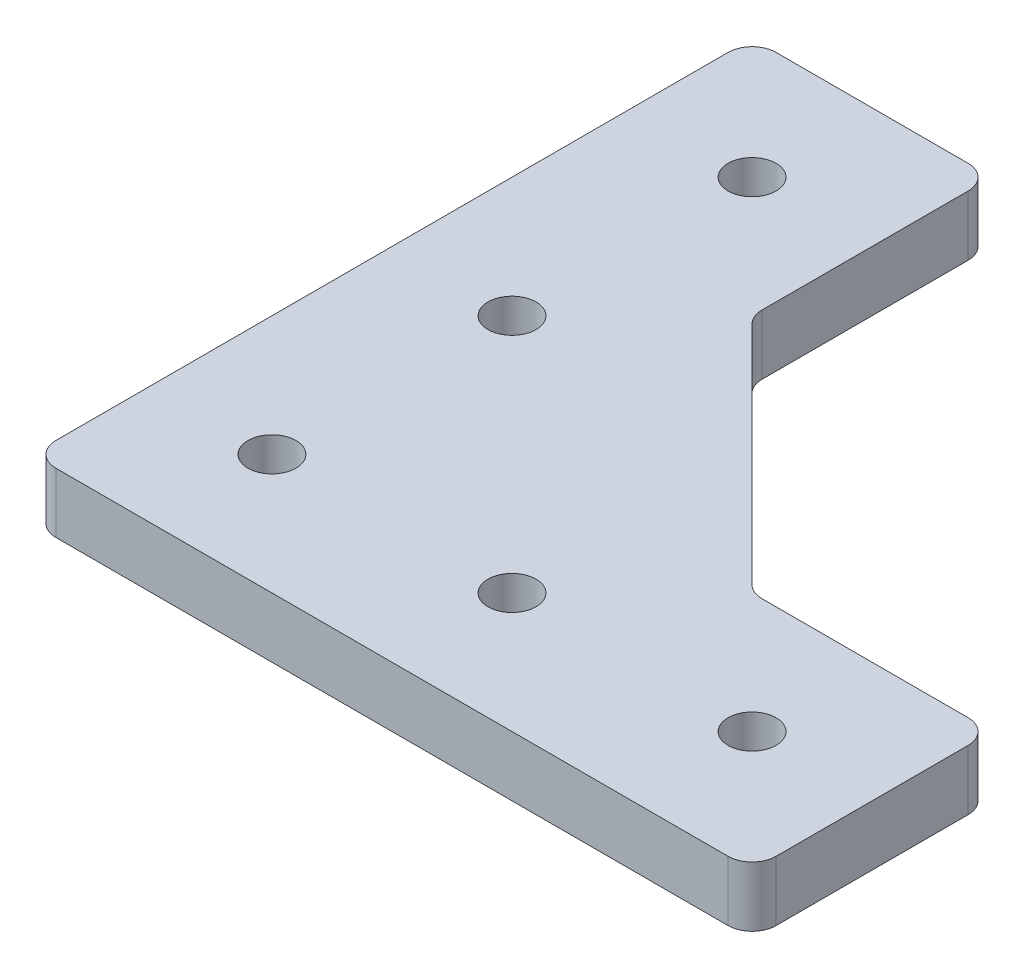
from build123d import *

# Parameters (mm, degrees)
SKETCH1_W           = 40
SKETCH1_H           = 20
SKETCH1_R           = 2
SKETCH1_W_2         = 20
SKETCH1_H_2         = 40
BOSS_EXTRUDE1_DEPTH = 5
FILLET1_R           = 2
BOSS_EXTRUDE2_DEPTH = 5
FILLET2_R           = 2


with BuildPart() as part:
    # Sketch1 → Boss-Extrude1 (new body)
    with BuildSketch(Plane(origin=(0, 0, 0), x_dir=(1, 0, 0), z_dir=(0, 1, 0))):
        with Locations((30, 0)):
            Rectangle(SKETCH1_W, SKETCH1_H)
        with Locations((20, 0)):
            Circle(SKETCH1_R, mode=Mode.SUBTRACT)
        with Locations((40, 0)):
            Circle(SKETCH1_R, mode=Mode.SUBTRACT)
        Rectangle(SKETCH1_W_2, SKETCH1_H)
        Circle(SKETCH1_R, mode=Mode.SUBTRACT)
        with Locations((0, 30)):
            Rectangle(SKETCH1_W_2, SKETCH1_H_2)
        with Locations((0, 20)):
            Circle(SKETCH1_R, mode=Mode.SUBTRACT)
        with Locations((0, 40)):
            Circle(SKETCH1_R, mode=Mode.SUBTRACT)
    extrude(amount=BOSS_EXTRUDE1_DEPTH)

    # Fillet1
    fillet1_edges = [part.edges().sort_by_distance(p)[0] for p in [
        (-10, 2.5, 10),
        (-10, 2.5, -50),
        (10, 2.5, -50),
        (10, 2.5, -10),
        (50, 2.5, -10),
        (50, 2.5, 10),
    ]]
    fillet(fillet1_edges, radius=FILLET1_R)

    # Sketch2 → Boss-Extrude2 (add)
    with BuildSketch(Plane(origin=(0, 5, 0), x_dir=(1, 0, 0), z_dir=(0, 1, 0))):
        Polygon((10, 30), (30, 10), (7.050252532, 7.050252532), align=None)
    extrude(amount=-BOSS_EXTRUDE2_DEPTH)

    # Fillet2
    fillet2_edges = [part.edges().sort_by_distance(p)[0] for p in [
        (10, 2.5, -30),
        (30, 2.5, -10),
    ]]
    fillet(fillet2_edges, radius=FILLET2_R)


solid = part.part
